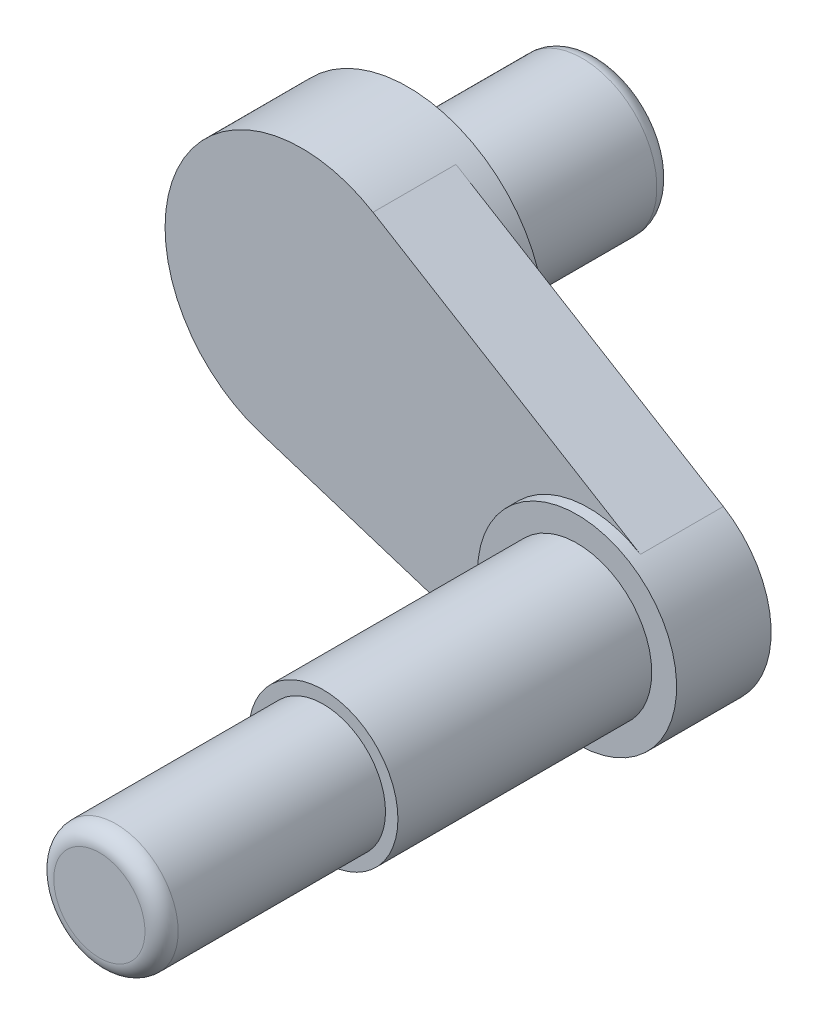
from build123d import *
from build123d.topology import SkipClean

# Parameters (mm, degrees)
Y_KSEKLIK_EKSTR_ZYON1_DEPTH = 50
IZIM4_R                     = 60
Y_KSEKLIK_EKSTR_ZYON2_DEPTH = 57
IZIM5_R                     = 45
Y_KSEKLIK_EKSTR_ZYON3_DEPTH = 153
IZIM6_R                     = 37.5
Y_KSEKLIK_EKSTR_ZYON4_DEPTH = 135
RADYUS1_R                   = 10


with BuildPart() as part:
    # Çizim1 → Döndür1 (revolve)
    with BuildSketch(Plane(origin=(0, 0, 0), x_dir=(0, 0, -1), z_dir=(1, 0, 0)), mode=Mode.PRIVATE) as d_nd_r1_sk:
        with BuildLine():
            Line((0, 0), (100, 0))
            Line((100, 0), (100, 35))
            ThreePointArc((100, 35), (97.071067812, 42.071067812), (90, 45))
            Line((90, 45), (0, 45))
            Line((0, 45), (0, 0))
        make_face()
        Polygon((-15, 0), (0, 0), (0, 45), (0, 50), (-15, 50), align=None)
        Polygon((-79, 0), (-15, 0), (-15, 50), (-15, 82.5), (-79, 82.5), align=None)
    revolve(d_nd_r1_sk.sketch.rotate(Axis((0, 0, -100), (0, 0, 1)), 90), axis=Axis((0, 0, -100), (0, 0, 1)))

    # Çizim2 → Yükseklik-Ekstrüzyon1 (add)
    with BuildSketch(Plane.XY.offset(79)):
        with BuildLine():
            Line((204.064670252, -27.524722616), (42.86153958, 70.492116048))
            Line((42.86153958, 70.492116048), (-25.081375274, -78.595003749))
            Line((-25.081375274, -78.595003749), (154.651641268, -135.951718832))
            ThreePointArc((154.651641268, -135.951718832), (227.490317719, -103.673310664), (204.064670252, -27.524722616))
        make_face()
    extrude(amount=-Y_KSEKLIK_EKSTR_ZYON1_DEPTH)

    # Çizim4 → Yükseklik-Ekstrüzyon2 (add)
    with SkipClean():  # the faces are left unmerged after this step: merging them gives an invalid solid
        with BuildSketch(Plane(origin=(0, 0, 29), x_dir=(-1, 0, 0), z_dir=(0, 0, -1))):
            with Locations(Location((-172.892641467, -78.791716105, 0), (0, 0, 121.300985795))):
                Circle(IZIM4_R)
        extrude(amount=-Y_KSEKLIK_EKSTR_ZYON2_DEPTH)

    # Çizim5 → Yükseklik-Ekstrüzyon3 (add)
    with SkipClean():  # the faces are left unmerged after this step: merging them gives an invalid solid
        with BuildSketch(Plane.XY.offset(86)):
            with Locations((172.892641467, -78.791716105)):
                Circle(IZIM5_R)
        extrude(amount=Y_KSEKLIK_EKSTR_ZYON3_DEPTH)

    # Çizim6 → Yükseklik-Ekstrüzyon4 (add)
    with SkipClean():  # the faces are left unmerged after this step: merging them gives an invalid solid
        with BuildSketch(Plane.XY.offset(239)):
            with Locations((172.892641467, -78.791716105)):
                Circle(IZIM6_R)
        extrude(amount=Y_KSEKLIK_EKSTR_ZYON4_DEPTH)

    # Radyus1
    radyus1_edges = [part.edges().sort_by_distance(p)[0] for p in [
        (135.392641467, -78.791716105, 374),
    ]]
    fillet(radyus1_edges, radius=RADYUS1_R)


solid = part.part
